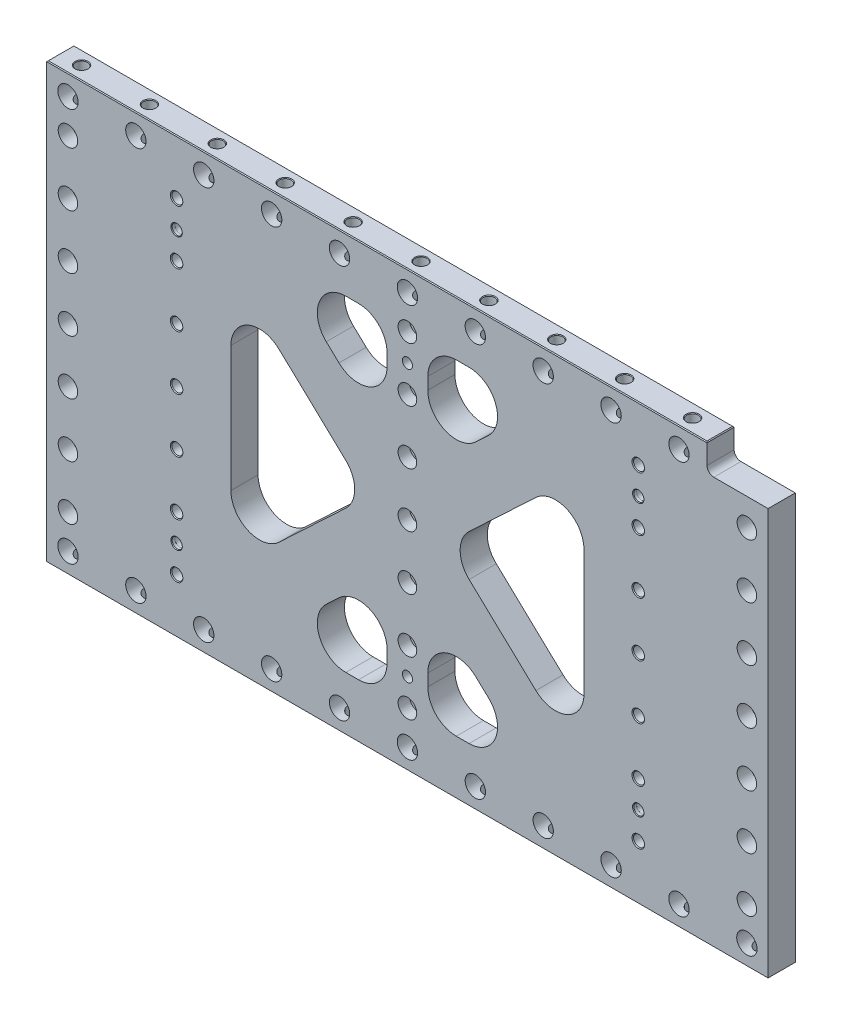
from build123d import *

# Parameters (mm, degrees)
SKETCH2_W                                     = 674.6875
SKETCH2_H                                     = 406.4
EXTRUDE1_DEPTH                                = 12.7
LPATTERN3_COUNT                               = 4
LPATTERN3_PITCH                               = 50.8
LPATTERN3_COL_COUNT                           = 4
LPATTERN3_COL_PITCH                           = 50.8
TRIANGLES_CUT_EXTRUDE2_DEPTH                  = 26.4
TRIANGLES_FILLET1_R                           = 26.67
SKETCH14_W                                    = 38.1
SKETCH14_H                                    = 406.4
EXTRUDE5_DEPTH                                = 25.4
FILLET3_R                                     = 26.67
LPATTERN5_COUNT                               = 4
LPATTERN5_PITCH                               = 50.8
LPATTERN5_COL_COUNT                           = 4
LPATTERN5_COL_PITCH                           = 50.8
F_3_4_0_75_DIAMETER_HOLE1_D                   = 19.05
LPATTERN4_COUNT                               = 6
LPATTERN4_PITCH                               = 63.5
LPATTERN4_COL_COUNT                           = 6
LPATTERN4_COL_PITCH                           = 63.5
F_3_4_0_75_DIAMETER_HOLE2_D                   = 19.05
LPATTERN6_COUNT                               = 6
LPATTERN6_PITCH                               = 63.5
LPATTERN6_COL_COUNT                           = 5
LPATTERN6_COL_PITCH                           = 63.5
SKETCH17_W                                    = 57.15
SKETCH17_H                                    = 25.4
CUT_EXTRUDE1_DEPTH                            = 25.4
FILLET4_R                                     = 6.35
CBORE_FOR_3_8_SOCKET_HEAD_CAP_SCREW1_AT_COUNT = 2
CBORE_FOR_3_8_SOCKET_HEAD_CAP_SCREW1_AT_PITCH = 50.8
CBORE_FOR_3_8_SOCKET_HEAD_CAP_SCREW1_2_COUNT  = 2
CBORE_FOR_3_8_SOCKET_HEAD_CAP_SCREW1_2_PITCH  = 101.6
CBORE_FOR_3_8_SOCKET_HEAD_CAP_SCREW1_3_COUNT  = 2
CBORE_FOR_3_8_SOCKET_HEAD_CAP_SCREW1_3_PITCH  = 152.4
CBORE_FOR_3_8_SOCKET_HEAD_CAP_SCREW1_4_COUNT  = 2
CBORE_FOR_3_8_SOCKET_HEAD_CAP_SCREW1_4_PITCH  = 203.2
CBORE_FOR_3_8_SOCKET_HEAD_CAP_SCREW1_5_COUNT  = 2
CBORE_FOR_3_8_SOCKET_HEAD_CAP_SCREW1_5_PITCH  = 254
CBORE_FOR_3_8_SOCKET_HEAD_CAP_SCREW1_6_COUNT  = 2
CBORE_FOR_3_8_SOCKET_HEAD_CAP_SCREW1_6_PITCH  = 304.8
F_3_8_0_375_PIN_LEAD_IN_HOLE1_AT_2_COUNT      = 2
F_3_8_0_375_PIN_LEAD_IN_HOLE1_AT_2_PITCH      = 254
F_3_8_0_375_PIN_LEAD_IN_HOLE2_AT_2_COUNT      = 2
F_3_8_0_375_PIN_LEAD_IN_HOLE2_AT_2_PITCH      = 254
F_3_8_0_375_PIN_LEAD_IN_HOLE2_AT_3_COUNT      = 2
F_3_8_0_375_PIN_LEAD_IN_HOLE2_AT_3_PITCH      = 500.966306252
F_3_8_0_375_PIN_LEAD_IN_HOLE2_AT_4_COUNT      = 2
F_3_8_0_375_PIN_LEAD_IN_HOLE2_AT_4_PITCH      = 431.8
CHAMFER1_SIZE                                 = 0.762


with BuildPart() as part:
    # Sketch2 → Extrude1 (new body, symmetric)
    with BuildSketch(Plane.XY):
        Rectangle(SKETCH2_W, SKETCH2_H)
    extrude(amount=EXTRUDE1_DEPTH, both=True)

    # Sketch3 → CBORE for 3/8 Socket Head Cap Screw3 (revolve, cut)
    with BuildSketch(Plane(origin=(-215.9, 0, -12.7), x_dir=(0, 1, 0), z_dir=(1, 0, 0))):
        Polygon((0, 0), (0, 25.4), (5.842, 25.4), (5.15874, 24.613999282), (5.15874, 10.668), (8.73125, 10.668), (8.73125, 0), align=None)
    cbore_for_3_8_socket_head_cap_screw3 = revolve(axis=Axis((-215.9, 0, -19.05), (0, 0, 1)), mode=Mode.SUBTRACT)

    # LPattern3: CBORE for 3/8 Socket Head Cap Screw3 ×4
    with Locations(*[(0, i * LPATTERN3_PITCH, 0) for i in range(1, LPATTERN3_COUNT)]):
        add(cbore_for_3_8_socket_head_cap_screw3, mode=Mode.SUBTRACT)

    # LPattern3 col: CBORE for 3/8 Socket Head Cap Screw3 ×4
    with Locations(*[(0, -i * LPATTERN3_COL_PITCH, 0) for i in range(1, LPATTERN3_COL_COUNT)]):
        add(cbore_for_3_8_socket_head_cap_screw3, mode=Mode.SUBTRACT)

    # Mirror1: CBORE for 3/8 Socket Head Cap Screw3 across plane
    add(cbore_for_3_8_socket_head_cap_screw3.mirror(Plane(origin=(0, 0, 0), x_dir=(0, 0, 1), z_dir=(1, 0, 0))), mode=Mode.SUBTRACT)

    # Mirror1 copy 1 sketch → Mirror1 copy 1 (revolve, cut)
    with BuildSketch(Plane(origin=(215.9, 50.8, -12.7), x_dir=(0, 1, 0), z_dir=(-1, 0, 0))):
        Polygon((0, 0), (0, -25.4), (5.842, -25.4), (5.15874, -24.613999282), (5.15874, -10.668), (8.73125, -10.668), (8.73125, 0), align=None)
    revolve(axis=Axis((215.9, 50.8, -19.05), (0, 0, -1)), mode=Mode.SUBTRACT)

    # Mirror1 copy 2 sketch → Mirror1 copy 2 (revolve, cut)
    with BuildSketch(Plane(origin=(215.9, 101.6, -12.7), x_dir=(0, 1, 0), z_dir=(-1, 0, 0))):
        Polygon((0, 0), (0, -25.4), (5.842, -25.4), (5.15874, -24.613999282), (5.15874, -10.668), (8.73125, -10.668), (8.73125, 0), align=None)
    revolve(axis=Axis((215.9, 101.6, -19.05), (0, 0, -1)), mode=Mode.SUBTRACT)

    # Mirror1 copy 3 sketch → Mirror1 copy 3 (revolve, cut)
    with BuildSketch(Plane(origin=(215.9, 152.4, -12.7), x_dir=(0, 1, 0), z_dir=(-1, 0, 0))):
        Polygon((0, 0), (0, -25.4), (5.842, -25.4), (5.15874, -24.613999282), (5.15874, -10.668), (8.73125, -10.668), (8.73125, 0), align=None)
    revolve(axis=Axis((215.9, 152.4, -19.05), (0, 0, -1)), mode=Mode.SUBTRACT)

    # Mirror1 copy 4 sketch → Mirror1 copy 4 (revolve, cut)
    with BuildSketch(Plane(origin=(215.9, -50.8, -12.7), x_dir=(0, 1, 0), z_dir=(-1, 0, 0))):
        Polygon((0, 0), (0, -25.4), (5.842, -25.4), (5.15874, -24.613999282), (5.15874, -10.668), (8.73125, -10.668), (8.73125, 0), align=None)
    revolve(axis=Axis((215.9, -50.8, -19.05), (0, 0, -1)), mode=Mode.SUBTRACT)

    # Mirror1 copy 5 sketch → Mirror1 copy 5 (revolve, cut)
    with BuildSketch(Plane(origin=(215.9, -101.6, -12.7), x_dir=(0, 1, 0), z_dir=(-1, 0, 0))):
        Polygon((0, 0), (0, -25.4), (5.842, -25.4), (5.15874, -24.613999282), (5.15874, -10.668), (8.73125, -10.668), (8.73125, 0), align=None)
    revolve(axis=Axis((215.9, -101.6, -19.05), (0, 0, -1)), mode=Mode.SUBTRACT)

    # Mirror1 copy 6 sketch → Mirror1 copy 6 (revolve, cut)
    with BuildSketch(Plane(origin=(215.9, -152.4, -12.7), x_dir=(0, 1, 0), z_dir=(-1, 0, 0))):
        Polygon((0, 0), (0, -25.4), (5.842, -25.4), (5.15874, -24.613999282), (5.15874, -10.668), (8.73125, -10.668), (8.73125, 0), align=None)
    revolve(axis=Axis((215.9, -152.4, -19.05), (0, 0, -1)), mode=Mode.SUBTRACT)

    # Sketch8 → Triangles -- Cut-Extrude2 (cut, through all)
    with BuildSketch(Plane.XY.offset(12.7)):
        Polygon((-165.1, 120.507707616), (-37.060560658, 0), (-165.1, -120.507707616), align=None)
        Polygon((-124.864439342, 152.4), (0, 34.880527678), (124.864439342, 152.4), align=None)
        Polygon((165.1, 120.507707616), (165.1, -120.507707616), (37.060560658, 0), align=None)
        Polygon((0, -34.880527678), (-124.864439342, -152.4), (124.864439342, -152.4), align=None)
    extrude(amount=-TRIANGLES_CUT_EXTRUDE2_DEPTH, mode=Mode.SUBTRACT)

    # Triangles -- Fillet1
    triangles_fillet1_edges = [part.edges().sort_by_distance(p)[0] for p in [
        (-165.1, -120.507707616, 0),
        (-165.1, 120.507707616, 0),
        (-37.060560658, 0, 0),
        (-124.864439342, 152.4, 0),
        (124.864439342, 152.4, 0),
        (0, 34.880527678, 0),
        (37.060560658, 0, 0),
        (165.1, 120.507707616, 0),
        (165.1, -120.507707616, 0),
        (0, -34.880527678, 0),
        (124.864439342, -152.4, 0),
        (-124.864439342, -152.4, 0),
    ]]
    fillet(triangles_fillet1_edges, radius=TRIANGLES_FILLET1_R)

    # Sketch14 → Extrude5 (add, through all)
    with BuildSketch(Plane.XY.offset(12.7)):
        Rectangle(SKETCH14_W, SKETCH14_H)
    extrude(amount=-EXTRUDE5_DEPTH)

    # Fillet3
    fillet3_edges = [part.edges().sort_by_distance(p)[0] for p in [
        (-19.05, -52.809939442, 0),
        (19.05, -152.4, 0),
        (19.05, 152.4, 0),
        (19.05, 52.809939442, 0),
        (19.05, -52.809939442, 0),
        (-19.05, 152.4, 0),
        (-19.05, -152.4, 0),
        (-19.05, 52.809939442, 0),
    ]]
    fillet(fillet3_edges, radius=FILLET3_R)

    # Sketch15 → CBORE for 3/8 Socket Head Cap Screw2 (revolve, cut)
    with BuildSketch(Plane(origin=(0, 0, 12.7), x_dir=(0, -1, 0), z_dir=(1, 0, 0))):
        Polygon((0, 0), (0, 25.4), (5.842, 25.4), (5.15874, 24.613999282), (5.15874, 10.668), (8.73125, 10.668), (8.73125, 0), align=None)
    cbore_for_3_8_socket_head_cap_screw2 = revolve(axis=Axis((0, 0, 19.05), (0, 0, -1)), mode=Mode.SUBTRACT)

    # LPattern5: CBORE for 3/8 Socket Head Cap Screw2 ×4
    with Locations(*[(0, i * LPATTERN5_PITCH, 0) for i in range(1, LPATTERN5_COUNT)]):
        add(cbore_for_3_8_socket_head_cap_screw2, mode=Mode.SUBTRACT)

    # LPattern5 col: CBORE for 3/8 Socket Head Cap Screw2 ×4
    with Locations(*[(0, -i * LPATTERN5_COL_PITCH, 0) for i in range(1, LPATTERN5_COL_COUNT)]):
        add(cbore_for_3_8_socket_head_cap_screw2, mode=Mode.SUBTRACT)

    # 3/4 (0.75) Diameter Hole1 (through all)
    with Locations(Plane.XY.offset(12.7)):
        with Locations((0, -184.15)):
            f_3_4_0_75_diameter_hole1 = Hole(F_3_4_0_75_DIAMETER_HOLE1_D / 2)

    # Sketch12 → 7/16 (0.4375) Diameter Hole1 (revolve, cut)
    with BuildSketch(Plane(origin=(0, -203.2, 0), x_dir=(0, 0, -1), z_dir=(1, 0, 0))):
        Polygon((0, 0), (0, 38.263531814), (5.55625, 34.925), (5.55625, 0.620911348), (6.096, 0), align=None)
    f_7_16_0_4375_diameter_hole1 = revolve(axis=Axis((0, -209.55, 0), (0, 1, 0)), mode=Mode.SUBTRACT)

    # LPattern4: 3/4 (0.75) Diameter Hole1, 7/16 (0.4375) Diameter Hole1 ×6
    with Locations(*[(i * LPATTERN4_PITCH, 0, 0) for i in range(1, LPATTERN4_COUNT)]):
        add(f_3_4_0_75_diameter_hole1, mode=Mode.SUBTRACT)
        add(f_7_16_0_4375_diameter_hole1, mode=Mode.SUBTRACT)

    # LPattern4 col: 3/4 (0.75) Diameter Hole1, 7/16 (0.4375) Diameter Hole1 ×6
    with Locations(*[(-i * LPATTERN4_COL_PITCH, 0, 0) for i in range(1, LPATTERN4_COL_COUNT)]):
        add(f_3_4_0_75_diameter_hole1, mode=Mode.SUBTRACT)
        add(f_7_16_0_4375_diameter_hole1, mode=Mode.SUBTRACT)

    # 3/4 (0.75) Diameter Hole2 (through all)
    with Locations(Plane.XY.offset(12.7)):
        with Locations((0, 184.15)):
            f_3_4_0_75_diameter_hole2 = Hole(F_3_4_0_75_DIAMETER_HOLE2_D / 2)

    # Sketch28 → 7/16 (0.4375) Diameter Hole2 (revolve, cut)
    with BuildSketch(Plane(origin=(0, 203.2, 0), x_dir=(0, 0, 1), z_dir=(1, 0, 0))):
        Polygon((0, 0), (0, 38.263531814), (5.55625, 34.925), (5.55625, 0.620911348), (6.096, 0), align=None)
    f_7_16_0_4375_diameter_hole2 = revolve(axis=Axis((0, 209.55, 0), (0, -1, 0)), mode=Mode.SUBTRACT)

    # LPattern6: 3/4 (0.75) Diameter Hole2, 7/16 (0.4375) Diameter Hole2 ×6
    with Locations(*[(-i * LPATTERN6_PITCH, 0, 0) for i in range(1, LPATTERN6_COUNT)]):
        add(f_3_4_0_75_diameter_hole2, mode=Mode.SUBTRACT)
        add(f_7_16_0_4375_diameter_hole2, mode=Mode.SUBTRACT)

    # LPattern6 col: 3/4 (0.75) Diameter Hole2, 7/16 (0.4375) Diameter Hole2 ×5
    with Locations(*[(i * LPATTERN6_COL_PITCH, 0, 0) for i in range(1, LPATTERN6_COL_COUNT)]):
        add(f_3_4_0_75_diameter_hole2, mode=Mode.SUBTRACT)
        add(f_7_16_0_4375_diameter_hole2, mode=Mode.SUBTRACT)

    # Sketch17 → Cut-Extrude1 (cut)
    with BuildSketch(Plane(origin=(0, 203.2, 0), x_dir=(1, 0, 0), z_dir=(0, 1, 0))):
        with Locations((308.76875, 0)):
            Rectangle(SKETCH17_W, SKETCH17_H)
    extrude(amount=-CUT_EXTRUDE1_DEPTH, mode=Mode.SUBTRACT)

    # Fillet4
    fillet4_edges = [part.edges().sort_by_distance(p)[0] for p in [
        (280.19375, 177.8, 0),
    ]]
    fillet(fillet4_edges, radius=FILLET4_R)

    # Sketch19 → CBORE for 3/8 Socket Head Cap Screw1 (revolve, cut)
    with BuildSketch(Plane(origin=(-317.5, 152.4, 12.7), x_dir=(0, -1, 0), z_dir=(1, 0, 0))):
        Polygon((0, 0), (0, 25.4), (6.35, 25.4), (5.55625, 24.486895077), (5.55625, 12.7), (9.128125, 12.7), (9.128125, 0), align=None)
    cbore_for_3_8_socket_head_cap_screw1 = revolve(axis=Axis((-317.5, 152.4, 19.05), (0, 0, -1)), mode=Mode.SUBTRACT)

    # CBORE for 3/8 Socket Head Cap Screw1 at: CBORE for 3/8 Socket Head Cap Screw1 ×2
    with Locations(*[(0, -i * CBORE_FOR_3_8_SOCKET_HEAD_CAP_SCREW1_AT_PITCH, 0) for i in range(1, CBORE_FOR_3_8_SOCKET_HEAD_CAP_SCREW1_AT_COUNT)]):
        add(cbore_for_3_8_socket_head_cap_screw1, mode=Mode.SUBTRACT)

    # CBORE for 3_8 Socket Head Cap Screw1 2: CBORE for 3/8 Socket Head Cap Screw1 ×2
    with Locations(*[(0, -i * CBORE_FOR_3_8_SOCKET_HEAD_CAP_SCREW1_2_PITCH, 0) for i in range(1, CBORE_FOR_3_8_SOCKET_HEAD_CAP_SCREW1_2_COUNT)]):
        add(cbore_for_3_8_socket_head_cap_screw1, mode=Mode.SUBTRACT)

    # CBORE for 3_8 Socket Head Cap Screw1 3: CBORE for 3/8 Socket Head Cap Screw1 ×2
    with Locations(*[(0, -i * CBORE_FOR_3_8_SOCKET_HEAD_CAP_SCREW1_3_PITCH, 0) for i in range(1, CBORE_FOR_3_8_SOCKET_HEAD_CAP_SCREW1_3_COUNT)]):
        add(cbore_for_3_8_socket_head_cap_screw1, mode=Mode.SUBTRACT)

    # CBORE for 3_8 Socket Head Cap Screw1 4: CBORE for 3/8 Socket Head Cap Screw1 ×2
    with Locations(*[(0, -i * CBORE_FOR_3_8_SOCKET_HEAD_CAP_SCREW1_4_PITCH, 0) for i in range(1, CBORE_FOR_3_8_SOCKET_HEAD_CAP_SCREW1_4_COUNT)]):
        add(cbore_for_3_8_socket_head_cap_screw1, mode=Mode.SUBTRACT)

    # CBORE for 3_8 Socket Head Cap Screw1 5: CBORE for 3/8 Socket Head Cap Screw1 ×2
    with Locations(*[(0, -i * CBORE_FOR_3_8_SOCKET_HEAD_CAP_SCREW1_5_PITCH, 0) for i in range(1, CBORE_FOR_3_8_SOCKET_HEAD_CAP_SCREW1_5_COUNT)]):
        add(cbore_for_3_8_socket_head_cap_screw1, mode=Mode.SUBTRACT)

    # CBORE for 3_8 Socket Head Cap Screw1 6: CBORE for 3/8 Socket Head Cap Screw1 ×2
    with Locations(*[(0, -i * CBORE_FOR_3_8_SOCKET_HEAD_CAP_SCREW1_6_PITCH, 0) for i in range(1, CBORE_FOR_3_8_SOCKET_HEAD_CAP_SCREW1_6_COUNT)]):
        add(cbore_for_3_8_socket_head_cap_screw1, mode=Mode.SUBTRACT)

    # Mirror3: CBORE for 3/8 Socket Head Cap Screw1 across plane
    add(cbore_for_3_8_socket_head_cap_screw1.mirror(Plane(origin=(0, 0, 0), x_dir=(0, 0, 1), z_dir=(1, 0, 0))), mode=Mode.SUBTRACT)

    # Mirror3 copy 1 sketch → Mirror3 copy 1 (revolve, cut)
    with BuildSketch(Plane(origin=(317.5, 101.6, 12.7), x_dir=(0, -1, 0), z_dir=(-1, 0, 0))):
        Polygon((0, 0), (0, -25.4), (6.35, -25.4), (5.55625, -24.486895077), (5.55625, -12.7), (9.128125, -12.7), (9.128125, 0), align=None)
    revolve(axis=Axis((317.5, 101.6, 19.05), (0, 0, 1)), mode=Mode.SUBTRACT)

    # Mirror3 copy 2 sketch → Mirror3 copy 2 (revolve, cut)
    with BuildSketch(Plane(origin=(317.5, 50.8, 12.7), x_dir=(0, -1, 0), z_dir=(-1, 0, 0))):
        Polygon((0, 0), (0, -25.4), (6.35, -25.4), (5.55625, -24.486895077), (5.55625, -12.7), (9.128125, -12.7), (9.128125, 0), align=None)
    revolve(axis=Axis((317.5, 50.8, 19.05), (0, 0, 1)), mode=Mode.SUBTRACT)

    # Mirror3 copy 3 sketch → Mirror3 copy 3 (revolve, cut)
    with BuildSketch(Plane(origin=(317.5, 0, 12.7), x_dir=(0, -1, 0), z_dir=(-1, 0, 0))):
        Polygon((0, 0), (0, -25.4), (6.35, -25.4), (5.55625, -24.486895077), (5.55625, -12.7), (9.128125, -12.7), (9.128125, 0), align=None)
    revolve(axis=Axis((317.5, 0, 19.05), (0, 0, 1)), mode=Mode.SUBTRACT)

    # Mirror3 copy 4 sketch → Mirror3 copy 4 (revolve, cut)
    with BuildSketch(Plane(origin=(317.5, -50.8, 12.7), x_dir=(0, -1, 0), z_dir=(-1, 0, 0))):
        Polygon((0, 0), (0, -25.4), (6.35, -25.4), (5.55625, -24.486895077), (5.55625, -12.7), (9.128125, -12.7), (9.128125, 0), align=None)
    revolve(axis=Axis((317.5, -50.8, 19.05), (0, 0, 1)), mode=Mode.SUBTRACT)

    # Mirror3 copy 5 sketch → Mirror3 copy 5 (revolve, cut)
    with BuildSketch(Plane(origin=(317.5, -101.6, 12.7), x_dir=(0, -1, 0), z_dir=(-1, 0, 0))):
        Polygon((0, 0), (0, -25.4), (6.35, -25.4), (5.55625, -24.486895077), (5.55625, -12.7), (9.128125, -12.7), (9.128125, 0), align=None)
    revolve(axis=Axis((317.5, -101.6, 19.05), (0, 0, 1)), mode=Mode.SUBTRACT)

    # Mirror3 copy 6 sketch → Mirror3 copy 6 (revolve, cut)
    with BuildSketch(Plane(origin=(317.5, -152.4, 12.7), x_dir=(0, -1, 0), z_dir=(-1, 0, 0))):
        Polygon((0, 0), (0, -25.4), (6.35, -25.4), (5.55625, -24.486895077), (5.55625, -12.7), (9.128125, -12.7), (9.128125, 0), align=None)
    revolve(axis=Axis((317.5, -152.4, 19.05), (0, 0, 1)), mode=Mode.SUBTRACT)

    # Sketch23 → 3/8 (0.375) Pin + Lead-In Hole1 (revolve, cut)
    with BuildSketch(Plane(origin=(0, 127, -12.7), x_dir=(0, 1, 0), z_dir=(1, 0, 0))):
        Polygon((0, 0), (0, 25.4), (4.7625, 25.4), (4.7625, 3.175), (4.7879, 3.175), (4.7879, 0.628216187), (5.334, 0), align=None)
    f_3_8_0_375_pin_lead_in_hole1 = revolve(axis=Axis((0, 127, -19.05), (0, 0, 1)), mode=Mode.SUBTRACT)

    # 3/8 (0.375) Pin + Lead-In Hole1 at 2: 3/8 (0.375) Pin + Lead-In Hole1 ×2
    with Locations(*[(0, -i * F_3_8_0_375_PIN_LEAD_IN_HOLE1_AT_2_PITCH, 0) for i in range(1, F_3_8_0_375_PIN_LEAD_IN_HOLE1_AT_2_COUNT)]):
        add(f_3_8_0_375_pin_lead_in_hole1, mode=Mode.SUBTRACT)

    # Sketch24 → 3/8 (0.375) Pin + Lead-In Hole2 (revolve, cut)
    with BuildSketch(Plane(origin=(-215.9, 127, 12.7), x_dir=(0, -1, 0), z_dir=(1, 0, 0))):
        Polygon((0, 0), (0, 25.4), (4.7625, 25.4), (4.7625, 3.175), (4.7879, 3.175), (4.7879, 0.628216187), (5.334, 0), align=None)
    f_3_8_0_375_pin_lead_in_hole2 = revolve(axis=Axis((-215.9, 127, 19.05), (0, 0, -1)), mode=Mode.SUBTRACT)

    # 3/8 (0.375) Pin + Lead-In Hole2 at 2: 3/8 (0.375) Pin + Lead-In Hole2 ×2
    with Locations(*[(0, -i * F_3_8_0_375_PIN_LEAD_IN_HOLE2_AT_2_PITCH, 0) for i in range(1, F_3_8_0_375_PIN_LEAD_IN_HOLE2_AT_2_COUNT)]):
        add(f_3_8_0_375_pin_lead_in_hole2, mode=Mode.SUBTRACT)

    # 3/8 (0.375) Pin + Lead-In Hole2 at 3: 3/8 (0.375) Pin + Lead-In Hole2 ×2
    with Locations(*[Vector(0.861934215, -0.507020127, 0) * (i * F_3_8_0_375_PIN_LEAD_IN_HOLE2_AT_3_PITCH) for i in range(1, F_3_8_0_375_PIN_LEAD_IN_HOLE2_AT_3_COUNT)]):
        add(f_3_8_0_375_pin_lead_in_hole2, mode=Mode.SUBTRACT)

    # 3/8 (0.375) Pin + Lead-In Hole2 at 4: 3/8 (0.375) Pin + Lead-In Hole2 ×2
    with Locations(*[(i * F_3_8_0_375_PIN_LEAD_IN_HOLE2_AT_4_PITCH, 0, 0) for i in range(1, F_3_8_0_375_PIN_LEAD_IN_HOLE2_AT_4_COUNT)]):
        add(f_3_8_0_375_pin_lead_in_hole2, mode=Mode.SUBTRACT)

    # Chamfer1
    chamfer1_edges = [part.edges().sort_by_distance(p)[0] for p in [
        (0, -203.2, -12.7),
        (0, -203.2, 12.7),
        (-337.34375, 203.2, 0),
        (337.34375, -203.2, 0),
        (-337.34375, -203.2, 0),
        (-28.575, 203.2, -12.7),
        (-28.575, 203.2, 12.7),
        (280.19375, 203.2, 0),
    ]]
    chamfer(chamfer1_edges, length=CHAMFER1_SIZE)


solid = part.part
